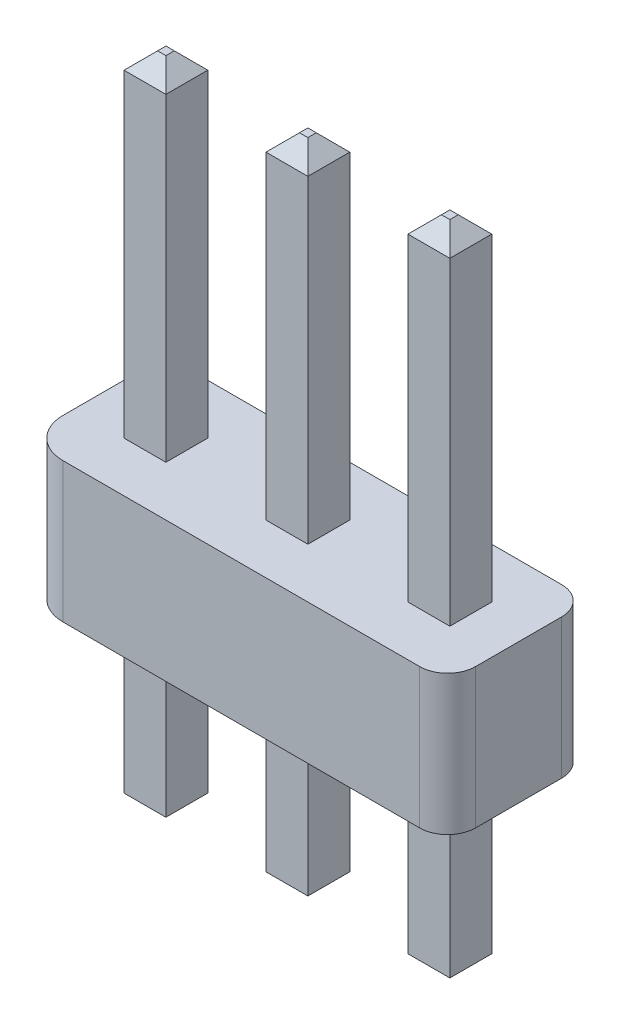
from build123d import *

# Parameters (mm, degrees)
BOSS_EXTRUDE1_DEPTH          = 2.5
SKETCH2_W                    = 0.75
SKETCH2_H                    = 0.75
BOSS_EXTRUDE2_DEPTH          = 8.5
BOSS_EXTRUDE2_DEPTH_BACK     = 3.25
CHAMFER1_SIZE                = 0.3
REDONDEO3_R                  = 0.7
CROQUIS5_W                   = 0.748499393
CROQUIS5_H                   = 0.75
SALIENTE_EXTRUIR4_DEPTH      = 5.7
SALIENTE_EXTRUIR4_DEPTH_BACK = 5.5
CROQUIS6_W                   = 0.748499393
CROQUIS6_H                   = 0.75
SALIENTE_EXTRUIR5_DEPTH      = 0.3
SALIENTE_EXTRUIR5_TAPER      = 45
CROQUIS7_W                   = 0.748499393
CROQUIS7_H                   = 0.75
SALIENTE_EXTRUIR6_DEPTH      = 0.3
SALIENTE_EXTRUIR6_TAPER      = 45


with BuildPart() as part:
    # Sketch1 → Boss-Extrude1 (new body)
    with BuildSketch(Plane(origin=(0, 0, 0), x_dir=(-1, 0, 0), z_dir=(0, 1, 0))):
        with BuildLine():
            Line((-2, 1.27), (2, 1.27))
            Line((2, 1.27), (4.545175415, 1.27))
            Line((4.545175415, 1.27), (5.081429124, 1.27))
            Line((5.081429124, 1.27), (5.081429124, -1.27))
            Line((5.081429124, -1.27), (4.545175415, -1.27))
            Line((4.545175415, -1.27), (2, -1.27))
            Line((2, -1.27), (-2, -1.27))
            ThreePointArc((-2, -1.27), (-2.353553391, -1.123553391), (-2.5, -0.77))
            Line((-2.5, -0.77), (-2.5, 0.77))
            ThreePointArc((-2.5, 0.77), (-2.353553391, 1.123553391), (-2, 1.27))
        make_face()
    extrude(amount=BOSS_EXTRUDE1_DEPTH)

    # Sketch2 → Boss-Extrude2 (add, two sides)
    with BuildSketch(Plane(origin=(0, 0, 0), x_dir=(-1, 0, 0), z_dir=(0, 1, 0))) as boss_extrude2_sk:
        with Locations((1.27, 0)):
            Rectangle(SKETCH2_W, SKETCH2_H)
        with Locations((-1.27, 0)):
            Rectangle(SKETCH2_W, SKETCH2_H)
    extrude(amount=BOSS_EXTRUDE2_DEPTH)
    extrude(boss_extrude2_sk.sketch, amount=-BOSS_EXTRUDE2_DEPTH_BACK)

    # Chamfer1
    chamfer1_edges = [part.edges().sort_by_distance(p)[0] for p in [
        (-0.895, -3.25, 0),
        (-1.27, -3.25, 0.375),
        (-1.645, -3.25, 0),
        (-1.27, -3.25, -0.375),
        (-0.895, 8.5, 0),
        (-1.27, 8.5, -0.375),
        (-1.645, 8.5, 0),
        (-1.27, 8.5, 0.375),
        (0.895, -3.25, 0),
        (1.27, -3.25, -0.375),
        (1.645, -3.25, 0),
        (1.27, -3.25, 0.375),
        (0.895, 8.5, 0),
        (1.27, 8.5, 0.375),
        (1.645, 8.5, 0),
        (1.27, 8.5, -0.375),
    ]]
    chamfer(chamfer1_edges, length=CHAMFER1_SIZE)

    # Redondeo3
    redondeo3_edges = [part.edges().sort_by_distance(p)[0] for p in [
        (-5.081429124, 1.25, 1.27),
        (-5.081429124, 1.25, -1.27),
    ]]
    fillet(redondeo3_edges, radius=REDONDEO3_R)

    # Croquis5 → Saliente-Extruir4 (add, two sides)
    with BuildSketch(Plane(origin=(0, 2.5, 0), x_dir=(1, 0, 0), z_dir=(0, 1, 0))) as saliente_extruir4_sk:
        with Locations((-3.809249697, 0)):
            Rectangle(CROQUIS5_W, CROQUIS5_H)
    extrude(amount=SALIENTE_EXTRUIR4_DEPTH)
    extrude(saliente_extruir4_sk.sketch, amount=-SALIENTE_EXTRUIR4_DEPTH_BACK)

    # Croquis6 → Saliente-Extruir5 (add)
    with BuildSketch(Plane(origin=(0, 8.2, 0), x_dir=(1, 0, 0), z_dir=(0, 1, 0))):
        with Locations((-3.809249697, 0)):
            Rectangle(CROQUIS6_W, CROQUIS6_H)
    extrude(amount=SALIENTE_EXTRUIR5_DEPTH, taper=SALIENTE_EXTRUIR5_TAPER)

    # Croquis7 → Saliente-Extruir6 (add)
    with BuildSketch(Plane.XZ.offset(3)):
        with Locations((-3.809249697, 0)):
            Rectangle(CROQUIS7_W, CROQUIS7_H)
    extrude(amount=SALIENTE_EXTRUIR6_DEPTH, taper=SALIENTE_EXTRUIR6_TAPER)


solid = part.part
